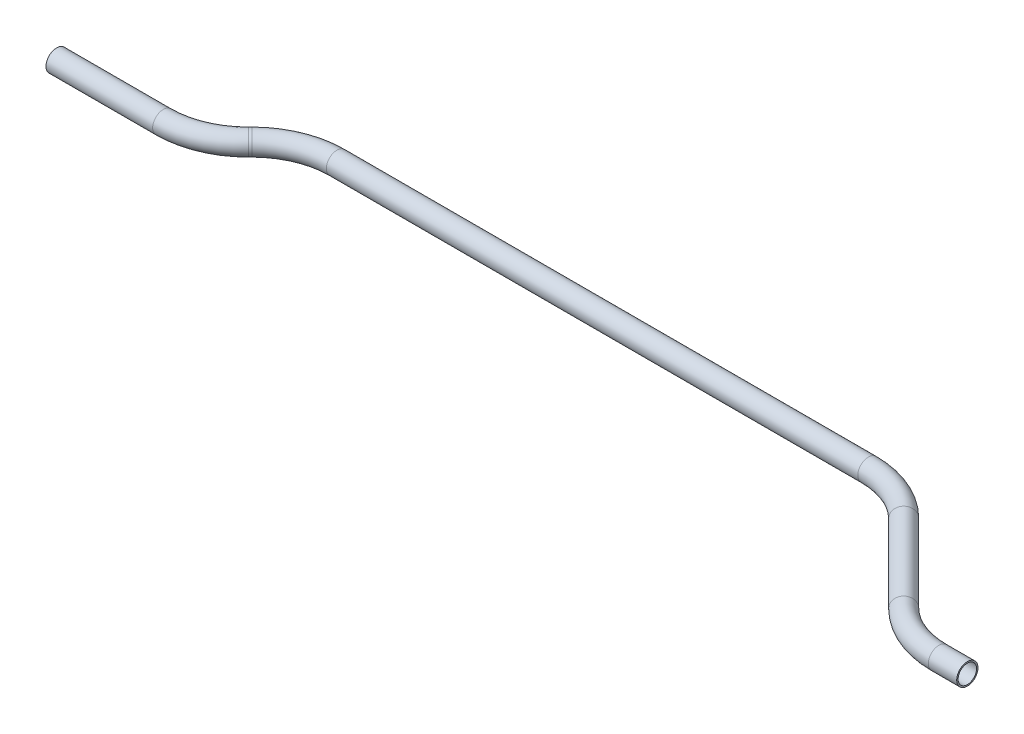
from build123d import *

# Parameters (mm, degrees)
SKETCH2_R   = 9.525
SKETCH2_R_2 = 8.2804


with BuildPart() as part:
    # Sweep1: sweep along a path in Sketch1
    with BuildLine(Plane(origin=(0, 0, 0), x_dir=(1, 0, 0), z_dir=(0, 1, 0))) as sweep1_path:
        Line((0, 0), (95.436926547, 0))
        ThreePointArc((95.436926547, 0), (124.597404093, 5.800379623), (149.318463274, 22.318463274))
        Line((149.318463274, 22.318463274), (150.825395518, 23.825395518))
        ThreePointArc((150.825395518, 23.825395518), (175.546454698, 40.343479169), (204.706932244, 46.143858792))
        Line((204.706932244, 46.143858792), (680.250251886, 46.143858792))
        ThreePointArc((680.250251886, 46.143858792), (709.410729432, 40.343479169), (734.131788612, 23.825395518))
        Line((734.131788612, 23.825395518), (803.794862065, -45.837677935))
        ThreePointArc((803.794862065, -45.837677935), (828.515921245, -62.355761586), (857.676398792, -68.156141208))
        Line((857.676398792, -68.156141208), (883.076398792, -68.156141208))
    # Sketch2 → Sweep1 (sweep)
    with BuildSketch(Plane(origin=(0, 0, 0), x_dir=(0, 0, -1), z_dir=(1, 0, 0))):
        Circle(SKETCH2_R)
        Circle(SKETCH2_R_2, mode=Mode.SUBTRACT)
    sweep(path=sweep1_path.line)


solid = part.part
